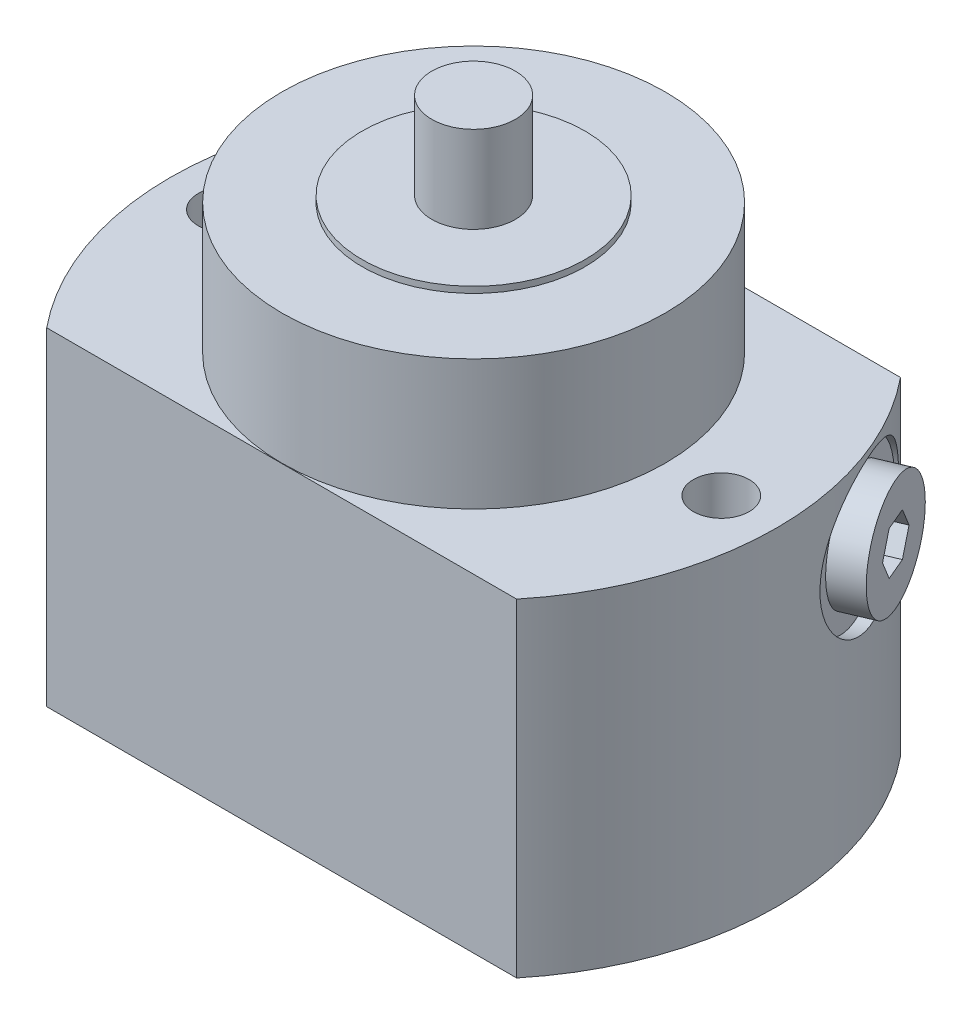
from build123d import *

# Parameters (mm, degrees)
EXTRUDE1_DEPTH     = 53
HOLE1_D            = 9
HOLE1_DEPTH        = 53
SKETCH5_R          = 4
CUT_EXTRUDE1_DEPTH = 4
SKETCH6_R          = 5.5
CUT_EXTRUDE2_DEPTH = 3
SKETCH7_R          = 2
CUT_EXTRUDE3_DEPTH = 33
CUT_EXTRUDE4_DEPTH = 5


with BuildPart() as part:
    # Sketch1 → Extrude1 (new body)
    with BuildSketch(Plane(origin=(0, 0, 0), x_dir=(1, 0, 0), z_dir=(0, 1, 0))):
        with BuildLine():
            Line((-37.947331922, 31), (37.947331922, 31))
            ThreePointArc((37.947331922, 31), (49, 0), (37.947331922, -31))
            Line((37.947331922, -31), (-37.947331922, -31))
            ThreePointArc((-37.947331922, -31), (-49, 0), (-37.947331922, 31))
        make_face()
    extrude(amount=EXTRUDE1_DEPTH)

    # Sketch2 → Revolve1 (revolve)
    with BuildSketch(Plane.XY, mode=Mode.PRIVATE) as revolve1_sk:
        Polygon((0, 89), (-6.75, 89), (-6.75, 75), (-18, 75), (-18, 74), (-30.95, 74), (-30.95, 53), (0, 53), align=None)
    revolve(revolve1_sk.sketch.rotate(Axis((0, 0, 0), (0, 1, 0)), 270), axis=Axis((0, 0, 0), (0, 1, 0)))  # turned: the seam where the file's is

    # Hole1
    with Locations(Plane(origin=(0, 53, 0), x_dir=(-1, 0, 0), z_dir=(0, 1, 0))):
        with Locations((40, 0), (-40, 0)):
            Hole(HOLE1_D / 2, depth=HOLE1_DEPTH)

    # Sketch5 → Cut-Extrude1 (cut)
    with BuildSketch(Plane.XZ):
        with Locations(Location((0, 0, 0), (0, 0, 270))):  # turned: the seam where the file's is
            Circle(SKETCH5_R)
    extrude(amount=-CUT_EXTRUDE1_DEPTH, mode=Mode.SUBTRACT)

    # Sketch6 → Cut-Extrude2 (cut)
    with BuildSketch(Plane.XZ):
        with Locations(Location((31, -13, 0), (0, 0, 270))):  # turned: the seam where the file's is
            Circle(SKETCH6_R)
    extrude(amount=-CUT_EXTRUDE2_DEPTH, mode=Mode.SUBTRACT)

    # Sketch7 → Cut-Extrude3 (cut)
    with BuildSketch(Plane.XZ.offset(-3)):
        with Locations(Location((31, -13, 0), (0, 0, 270))):  # turned: the seam where the file's is
            Circle(SKETCH7_R)
    extrude(amount=-CUT_EXTRUDE3_DEPTH, mode=Mode.SUBTRACT)

    # Sketch8 → Cut-Revolve1 (revolve, cut)
    with BuildSketch(Plane(origin=(0, 0, 0), x_dir=(0.920504853, 0, -0.390731128), z_dir=(0.390731128, 0, 0.920504853)), mode=Mode.PRIVATE) as cut_revolve1_sk:
        Polygon((49, 28), (47, 28), (47, 33.4215), (45.517364509, 34.2775), (32, 34.2775), (32, 40), (49, 40), align=None)
    revolve(cut_revolve1_sk.sketch.rotate(Axis((47.484793311, 40, -20.156098913), (-0.920504853, 0, 0.390731128)), 270), axis=Axis((47.484793311, 40, -20.156098913), (-0.920504853, 0, 0.390731128)), mode=Mode.SUBTRACT)  # turned: the seam where the file's is

    # Sketch9 → Revolve2 (revolve)
    with BuildSketch(Plane(origin=(0, 0, 0), x_dir=(0.920504853, 0, -0.390731128), z_dir=(0.390731128, 0, 0.920504853)), mode=Mode.PRIVATE) as revolve2_sk:
        Polygon((47, 31), (47, 34.2775), (38, 34.2775), (37, 35.2775), (37, 40), (52, 40), (52, 31), align=None)
    revolve(revolve2_sk.sketch.rotate(Axis((53.930450878, 40, -22.892118224), (-0.920504853, 0, 0.390731128)), 270), axis=Axis((53.930450878, 40, -22.892118224), (-0.920504853, 0, 0.390731128)))  # turned: the seam where the file's is

    # Sketch10 → Cut-Extrude4 (cut)
    with BuildSketch(Plane(origin=(47.86625238, 0, -20.318018681), x_dir=(-0.390731128, 0, -0.920504853), z_dir=(0.920504853, 0, -0.390731128))):
        Polygon((4.041451884, 40), (2.020725942, 43.5), (-2.020725942, 43.5), (-4.041451884, 40), (-2.020725942, 36.5), (2.020725942, 36.5), align=None)
    extrude(amount=-CUT_EXTRUDE4_DEPTH, mode=Mode.SUBTRACT)


solid = part.part
